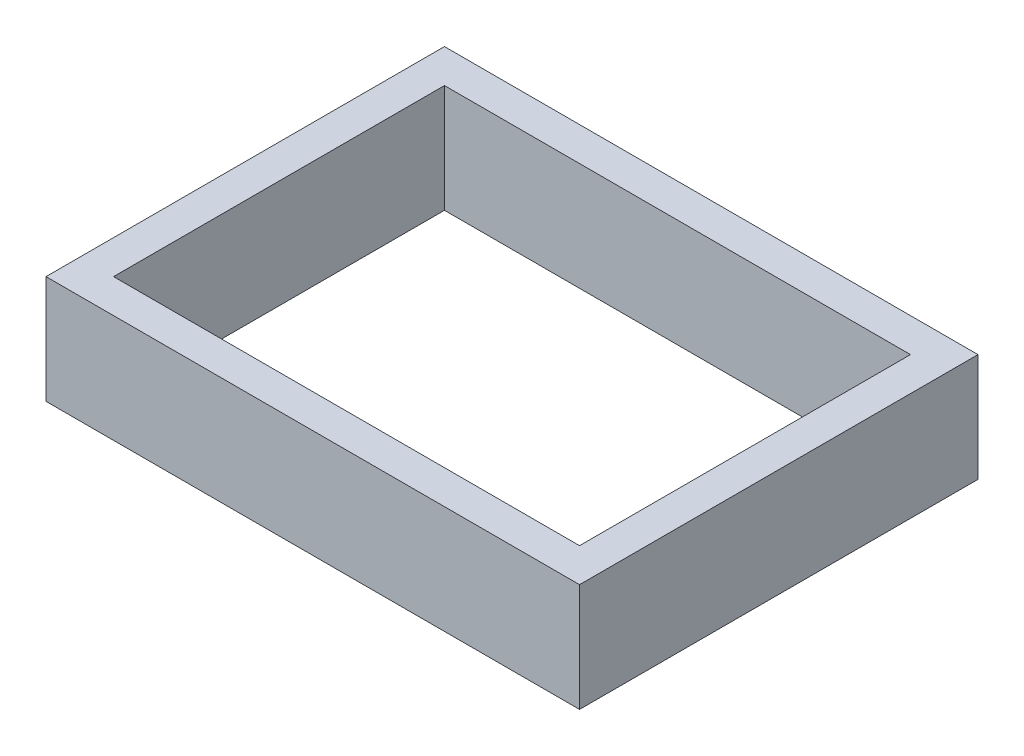
from build123d import *

# Parameters (mm, degrees)
SKETCH1_W           = 1003.3
SKETCH1_H           = 749.3
SKETCH1_W_2         = 876.3
SKETCH1_H_2         = 622.3
BOSS_EXTRUDE1_DEPTH = 203.2


with BuildPart() as part:
    # Sketch1 → Boss-Extrude1 (new body)
    with BuildSketch(Plane(origin=(0, 101.6, 0), x_dir=(1, 0, 0), z_dir=(0, 1, 0))):
        with Locations((-438.15, 311.15)):
            Rectangle(SKETCH1_W, SKETCH1_H)
        with Locations((-438.15, 311.15)):
            Rectangle(SKETCH1_W_2, SKETCH1_H_2, mode=Mode.SUBTRACT)
    extrude(amount=BOSS_EXTRUDE1_DEPTH)


solid = part.part
